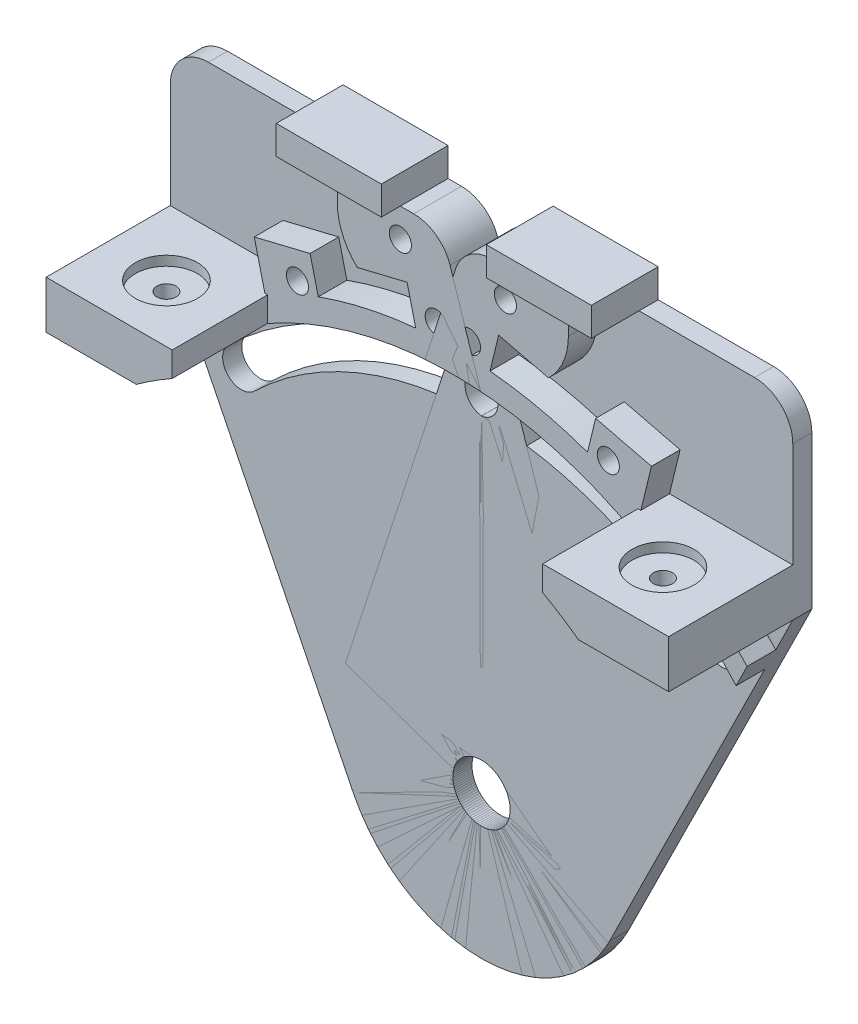
from build123d import *

# Parameters (mm, degrees)
SKETCH2_R                = 3.81
BOSS_EXTRUDE1_DEPTH      = 2.54
SKETCH5_W                = 16.764
SKETCH5_H                = 6.35
BOSS_EXTRUDE2_DEPTH      = 16.51
SKETCH6_R                = 4.1275
CUT_EXTRUDE2_DEPTH       = 1.27
SKETCH7_R                = 1.27
CUT_EXTRUDE3_DEPTH       = 65.77
CUT_EXTRUDE4_DEPTH       = 2.286
BOSS_EXTRUDE3_DEPTH      = 3.81
F_4_CLEARANCE_HOLE1_D    = 2.9464
SKETCH14_W               = 13.97
SKETCH14_H               = 3.81
BOSS_EXTRUDE6_DEPTH      = 6.35
BOSS_EXTRUDE6_DEPTH_BACK = 2.54
FILLET1_R                = 5.08
CUT_EXTRUDE5_DEPTH       = 3.54
BOSS_EXTRUDE7_DEPTH      = 3.81
CUT_EXTRUDE7_DEPTH       = 17.51


with BuildPart() as part:
    # Sketch2 → Boss-Extrude1 (new body)
    with BuildSketch(Plane.XY):
        with BuildLine():
            Line((-17.068825413, -8.459178389), (-41.402, 40.64))
            Line((-41.402, 40.64), (-41.402, 66.04))
            Line((-41.402, 66.04), (-1.524, 66.04))
            Line((-1.524, 66.04), (18.109053667, 5.913093546))
            ThreePointArc((18.109053667, 5.913093546), (7.204933647, -17.634949139), (-17.068825413, -8.459178389))
        make_face()
        Circle(SKETCH2_R, mode=Mode.SUBTRACT)
    extrude(amount=BOSS_EXTRUDE1_DEPTH)

    # Sketch5 → Boss-Extrude2 (add)
    with BuildSketch(Plane.XY.offset(2.54)):
        with Locations((-33.02, 43.815)):
            Rectangle(SKETCH5_W, SKETCH5_H)
    extrude(amount=BOSS_EXTRUDE2_DEPTH)

    # Sketch6 → Cut-Extrude2 (cut)
    with BuildSketch(Plane(origin=(0, 46.99, 0), x_dir=(1, 0, 0), z_dir=(0, 1, 0))):
        with Locations((-33.02, -11.43)):
            Circle(SKETCH6_R)
    extrude(amount=-CUT_EXTRUDE2_DEPTH, mode=Mode.SUBTRACT)

    # Sketch7 → Cut-Extrude3 (cut, through all)
    with BuildSketch(Plane(origin=(0, 45.72, 0), x_dir=(1, 0, 0), z_dir=(0, 1, 0))):
        with Locations((-33.02, -11.43)):
            Circle(SKETCH7_R)
    extrude(amount=-CUT_EXTRUDE3_DEPTH, mode=Mode.SUBTRACT)

    # Sketch9 → Cut-Extrude4 (cut)
    with BuildSketch(Plane(origin=(0, 0, 0), x_dir=(-1, 0, 0), z_dir=(0, 0, -1))):
        Polygon((3.171122265, 62.23), (5.077532854, 58.928), (8.890354032, 58.928), (10.796764621, 62.23), (8.890354032, 65.532), (5.077532854, 65.532), align=None)
        Polygon((24.379877895, 49.663956202), (23.308143816, 53.323053276), (19.603405755, 54.224452874), (16.970401774, 51.466755398), (18.042135853, 47.807658324), (21.746873914, 46.906258726), align=None)
        Polygon((5.918476139, 54.15579827), (4.846742059, 57.814895344), (1.142003999, 58.716294942), (-1.490999983, 55.958597466), (-0.419265903, 52.299500392), (3.285472157, 51.398100794), align=None)
    extrude(amount=-CUT_EXTRUDE4_DEPTH, mode=Mode.SUBTRACT)

    # Sketch8 → Boss-Extrude3 (add)
    with BuildSketch(Plane.XY.offset(2.54)):
        with BuildLine():
            Line((-15.367, 66.04), (-6.983943443, 66.04))
            Line((-6.983943443, 66.04), (-1.524, 66.04))
            Line((-1.524, 66.04), (3.09175139, 51.904101595))
            Line((3.09175139, 51.904101595), (-4.240438106, 50.120107003))
            Line((-4.240438106, 50.120107003), (-6.088713216, 57.716488409))
            Line((-6.088713216, 57.716488409), (-12.708473154, 56.10583501))
            ThreePointArc((-12.708473154, 56.10583501), (-14.673699407, 58.891843255), (-15.367, 62.23))
            Line((-15.367, 62.23), (-15.367, 66.04))
        make_face()
        Polygon((-17.142042414, 46.981018422), (-18.990317524, 54.577399829), (-26.415687706, 52.770733449), (-24.567412596, 45.174352043), align=None)
    extrude(amount=BOSS_EXTRUDE3_DEPTH)

    # #4 Clearance Hole1 (through all)
    with Locations(Plane.XY.offset(6.35)):
        with Locations((-6.983943443, 62.23), (-20.675139834, 50.5653558), (-2.213738078, 55.057197868)):
            Hole(F_4_CLEARANCE_HOLE1_D / 2)

    # Sketch14 → Boss-Extrude6 (add, two sides)
    with BuildSketch(Plane.XY.offset(2.54)) as boss_extrude6_sk:
        with Locations((-13.968943443, 67.945)):
            Rectangle(SKETCH14_W, SKETCH14_H)
    extrude(amount=BOSS_EXTRUDE6_DEPTH)
    extrude(boss_extrude6_sk.sketch, amount=-BOSS_EXTRUDE6_DEPTH_BACK)

    # Fillet1
    fillet1_edges = [part.edges().sort_by_distance(p)[0] for p in [
        (-1.524, 66.04, 3.175),
        (-41.402, 66.04, 1.27),
    ]]
    fillet(fillet1_edges, radius=FILLET1_R)

    # Sketch15 → Cut-Extrude5 (cut, through all)
    with BuildSketch(Plane.XY.offset(2.54)):
        with BuildLine():
            ThreePointArc((-0.315167053, 48.411374113), (-18.310138041, 44.816284079), (-33.674369734, 34.782140486))
            ThreePointArc((-33.674369734, 34.782140486), (-33.731327517, 31.262340905), (-30.211527936, 31.205383122))
            ThreePointArc((-30.211527936, 31.205383122), (-16.427248714, 40.207684038), (-0.28275743, 43.433079608))
            ThreePointArc((-0.28275743, 43.433079608), (2.190185011, 45.938431672), (-0.315167053, 48.411374113))
        make_face()
    extrude(amount=-CUT_EXTRUDE5_DEPTH, mode=Mode.SUBTRACT)

    # Sketch18 → Boss-Extrude7 (add)
    with BuildSketch(Plane.XY.offset(2.54)):
        with BuildLine():
            ThreePointArc((-17.178757335, 47.131916166), (-6.891074177, 49.689438734), (3.704334892, 50.028043416))
            Line((3.704334892, 50.028043416), (3.09175139, 51.904101595))
            Line((3.09175139, 51.904101595), (-4.240438106, 50.120107003))
            Line((-4.240438106, 50.120107003), (-4.941378488, 53.000960864))
            ThreePointArc((-4.941378488, 53.000960864), (-11.514519489, 51.97051967), (-17.907769463, 50.128144457))
            Line((-17.907769463, 50.128144457), (-17.178757335, 47.131916166))
        make_face()
        with BuildLine():
            ThreePointArc((-24.638, 43.697782335), (-21.550057665, 45.300355844), (-18.358466971, 46.685050235))
            Line((-18.358466971, 46.685050235), (-24.567412596, 45.174352043))
            Line((-24.567412596, 45.174352043), (-24.638, 45.464465155))
            Line((-24.638, 45.464465155), (-24.638, 43.697782335))
        make_face()
        with BuildLine():
            Line((-39.140530204, 36.076834246), (-37.675988959, 33.121701057))
            ThreePointArc((-37.675988959, 33.121701057), (-33.75272292, 37.111735617), (-29.409481889, 40.64))
            Line((-29.409481889, 40.64), (-34.378910307, 40.64))
            ThreePointArc((-34.378910307, 40.64), (-36.830458233, 38.432231528), (-39.140530204, 36.076834246))
        make_face()
    extrude(amount=BOSS_EXTRUDE7_DEPTH)

    # Sketch16 → Cut-Extrude7 (cut, through all)
    with BuildSketch(Plane.XY.offset(2.54)):
        with BuildLine():
            ThreePointArc((-0.326576563, 50.163936974), (-18.972991936, 46.4386994), (-34.893431388, 36.041305068))
            ThreePointArc((-34.893431388, 36.041305068), (-34.990492099, 30.043279251), (-28.992466282, 29.94621854))
            ThreePointArc((-28.992466282, 29.94621854), (-15.764394819, 38.585268717), (-0.271347919, 41.680516747))
            ThreePointArc((-0.271347919, 41.680516747), (3.942747872, 45.949841182), (-0.326576563, 50.163936974))
        make_face()
    extrude(amount=CUT_EXTRUDE7_DEPTH, mode=Mode.SUBTRACT)


with BuildPart() as body_2:
    # Mirror1: mirrored copy
    add(part.part.mirror(Plane(origin=(0, 0, 0), x_dir=(0, 0, 1), z_dir=(1, 0, 0))))


solid = Compound([part.part, body_2.part])
